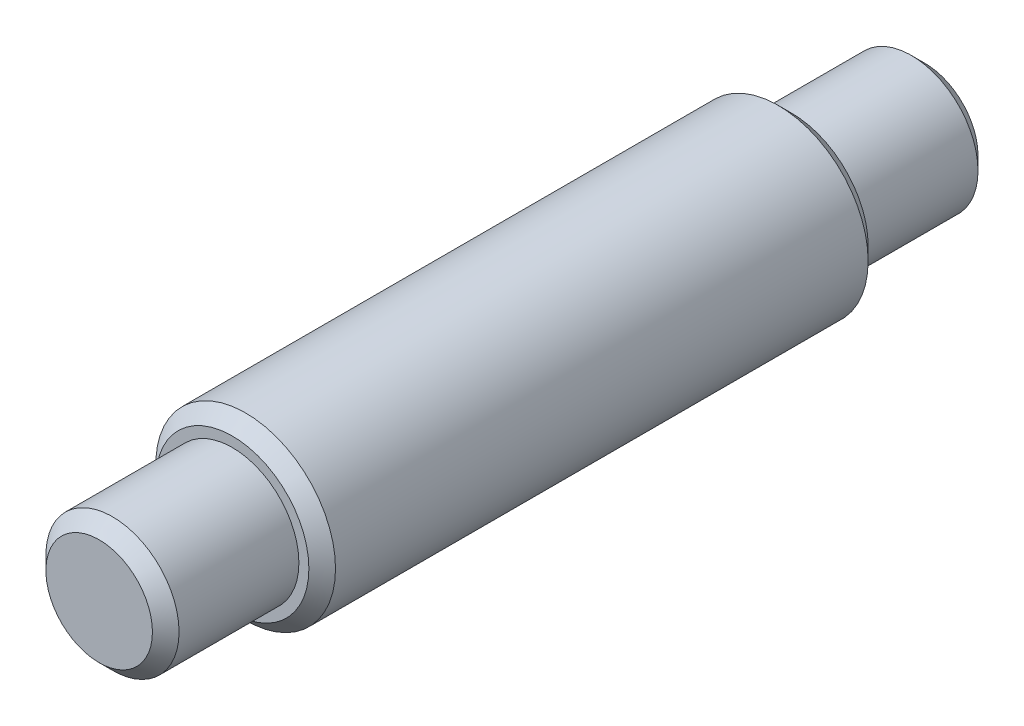
from build123d import *

# Parameters (mm, degrees)
SKETCH1_R           = 0.25
BOSS_EXTRUDE1_DEPTH = 1.55
SKETCH3_R           = 0.3375
BOSS_EXTRUDE2_DEPTH = 1.05
CHAMFER1_SIZE       = 0.05


with BuildPart() as part:
    # Sketch1 → Boss-Extrude1 (new body, symmetric)
    with BuildSketch(Plane.XY):
        Circle(SKETCH1_R)
    extrude(amount=BOSS_EXTRUDE1_DEPTH, both=True)

    # Sketch3 → Boss-Extrude2 (add, symmetric)
    with BuildSketch(Plane.XY):
        Circle(SKETCH3_R)
    extrude(amount=BOSS_EXTRUDE2_DEPTH, both=True)

    # Chamfer1
    chamfer1_edges = [part.edges().sort_by_distance(p)[0] for p in [
        (-0.25, 0, 1.55),
        (-0.25, 0, -1.55),
        (-0.3375, 0, -1.05),
        (-0.3375, 0, 1.05),
    ]]
    chamfer(chamfer1_edges, length=CHAMFER1_SIZE)


solid = part.part
